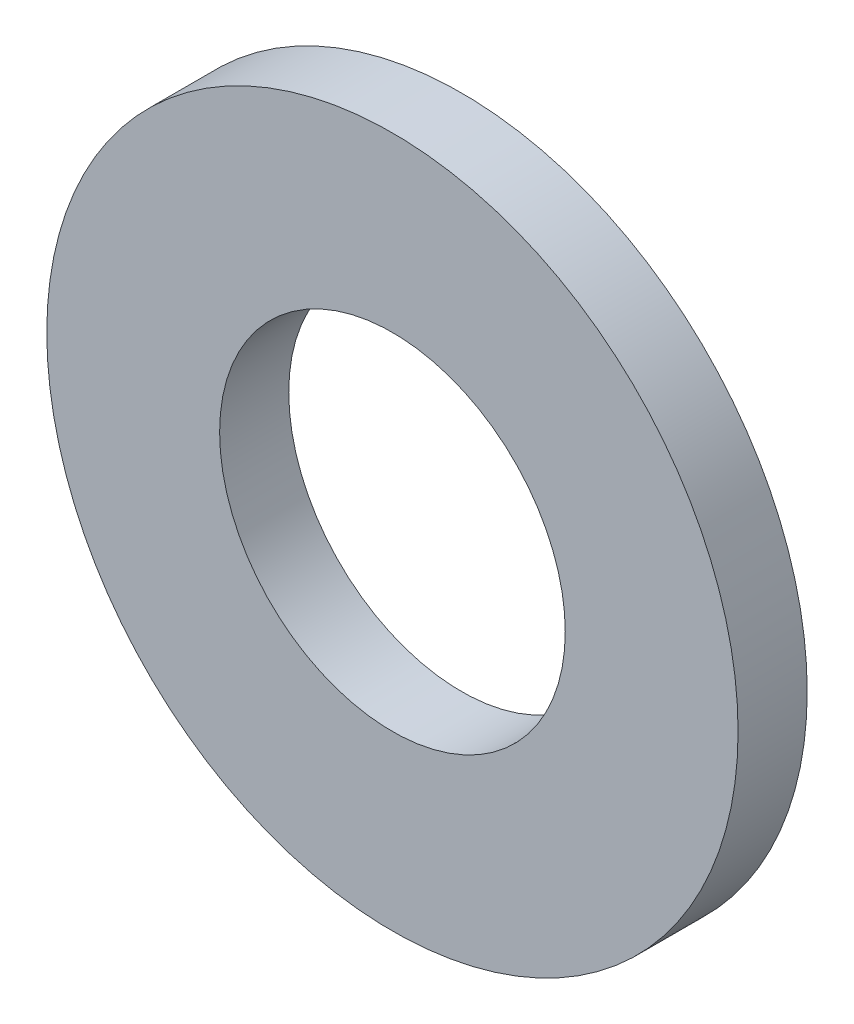
from build123d import *

# Parameters (mm, degrees)
SKETCH1_R           = 2
SKETCH1_R_2         = 1
BOSS_EXTRUDE1_DEPTH = 0.4


with BuildPart() as part:
    # Sketch1 → Boss-Extrude1 (new body)
    with BuildSketch(Plane.XY):
        Circle(SKETCH1_R)
        Circle(SKETCH1_R_2, mode=Mode.SUBTRACT)
    extrude(amount=BOSS_EXTRUDE1_DEPTH)


solid = part.part
